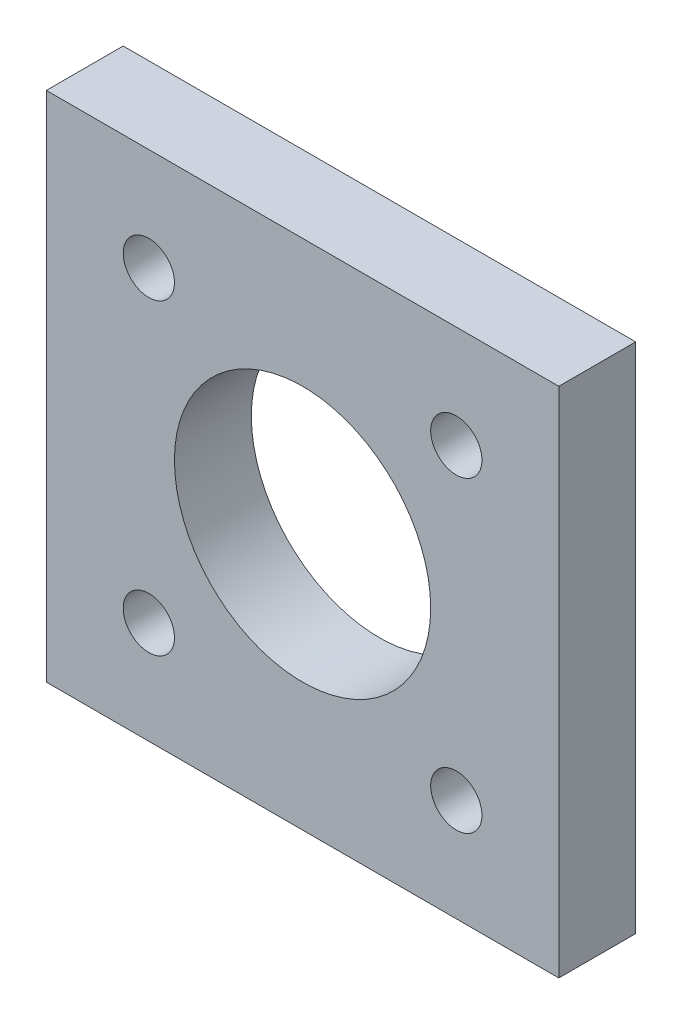
from build123d import *

# Parameters (mm, degrees)
SKETCH1_W           = 40
SKETCH1_H           = 40
SKETCH1_R           = 10
SKETCH1_R_2         = 2
BOSS_EXTRUDE1_DEPTH = 6


with BuildPart() as part:
    # Sketch1 → Boss-Extrude1 (new body)
    with BuildSketch(Plane.XY):
        Rectangle(SKETCH1_W, SKETCH1_H)
        Circle(SKETCH1_R, mode=Mode.SUBTRACT)
        with Locations((-12, 12)):
            Circle(SKETCH1_R_2, mode=Mode.SUBTRACT)
        with Locations((12, 12)):
            Circle(SKETCH1_R_2, mode=Mode.SUBTRACT)
        with Locations((12, -12)):
            Circle(SKETCH1_R_2, mode=Mode.SUBTRACT)
        with Locations((-12, -12)):
            Circle(SKETCH1_R_2, mode=Mode.SUBTRACT)
    extrude(amount=BOSS_EXTRUDE1_DEPTH)


solid = part.part
